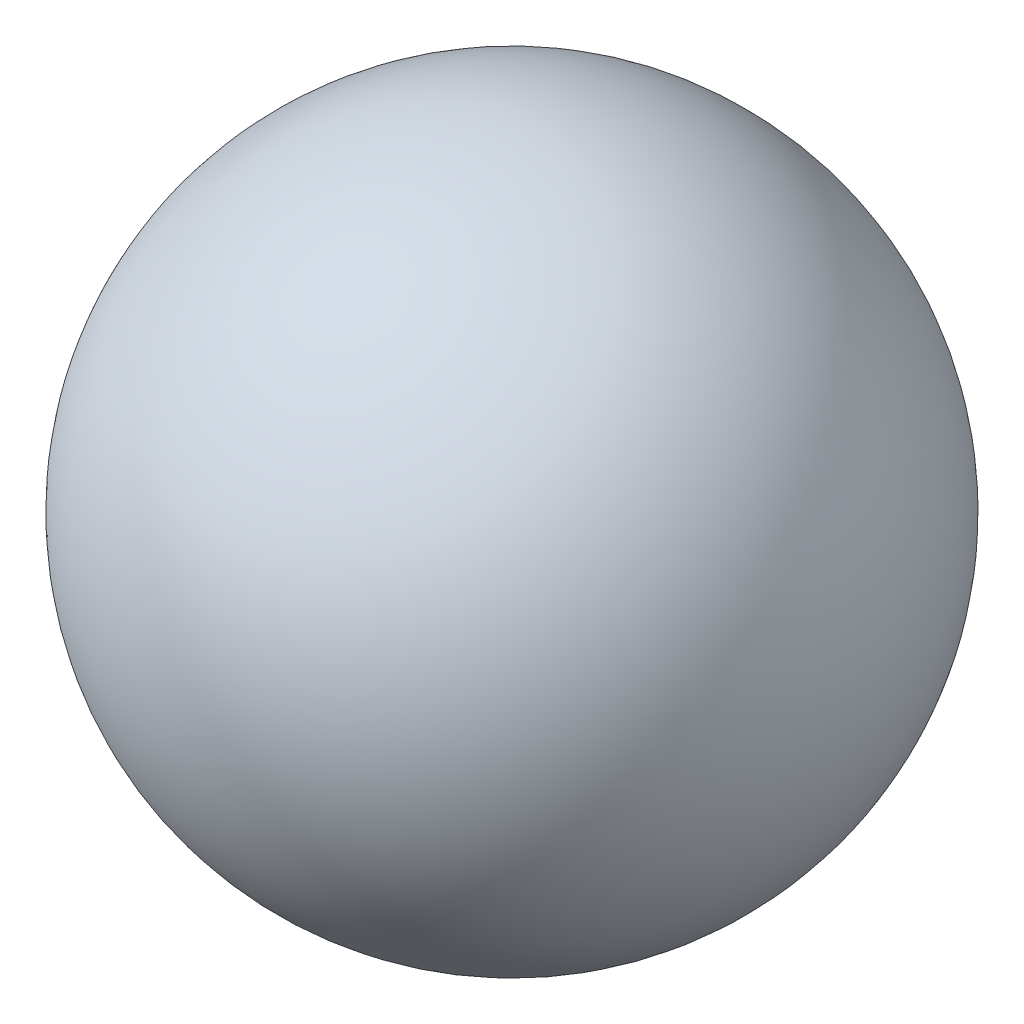
from build123d import *


with BuildPart() as part:
    # 草图1 → 旋转1 (revolve)
    with BuildSketch(Plane.XY):
        with BuildLine():
            Line((3.6905, 9.75), (1.3095, 9.75))
            ThreePointArc((1.3095, 9.75), (2.5, 10.9405), (3.6905, 9.75))
        make_face()
    revolve(axis=Axis((3.6905, 9.75, 0), (-1, 0, 0)))


solid = part.part
